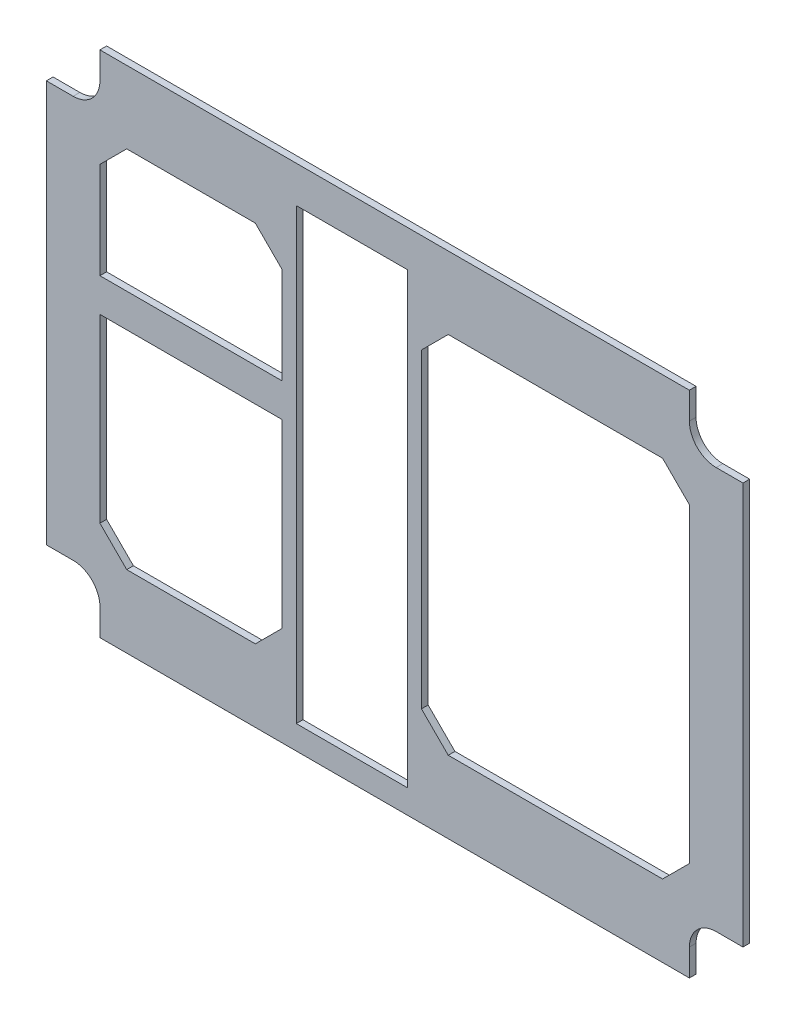
from build123d import *

# Parameters (mm, degrees)
SKETCH1_W           = 20.32
SKETCH1_H           = 100.33
BOSS_EXTRUDE1_DEPTH = 1.5875
SKETCH2_W           = 26.32
SKETCH2_H           = 106.33
CUT_EXTRUDE1_DEPTH  = 2.5875


with BuildPart() as part:
    # Sketch1 → Boss-Extrude1 (new body)
    with BuildSketch(Plane.XY):
        with BuildLine():
            Line((0, -12.7), (-6.35, -12.7))
            ThreePointArc((-6.35, -12.7), (-10.840128061, -10.840128061), (-12.7, -6.35))
            Line((-12.7, -6.35), (-12.7, 0))
            Line((-12.7, 0), (-152.4, 0))
            Line((-152.4, 0), (-152.4, -6.35))
            ThreePointArc((-152.4, -6.35), (-154.259871939, -10.840128061), (-158.75, -12.7))
            Line((-158.75, -12.7), (-165.1, -12.7))
            Line((-165.1, -12.7), (-165.1, -107.95))
            Line((-165.1, -107.95), (-158.75, -107.95))
            ThreePointArc((-158.75, -107.95), (-154.259871939, -109.809871939), (-152.4, -114.3))
            Line((-152.4, -114.3), (-152.4, -120.65))
            Line((-152.4, -120.65), (-12.7, -120.65))
            Line((-12.7, -120.65), (-12.7, -114.3))
            ThreePointArc((-12.7, -114.3), (-10.840128061, -109.809871939), (-6.35, -107.95))
            Line((-6.35, -107.95), (0, -107.95))
            Line((0, -107.95), (0, -12.7))
        make_face()
        with Locations((-92.71, -61.849)):
            Rectangle(SKETCH1_W, SKETCH1_H, mode=Mode.SUBTRACT)
        Polygon((-19.05, -17.145), (-69.85, -17.145), (-76.2, -23.495), (-76.2, -97.155), (-69.85, -103.505), (-19.05, -103.505), (-12.7, -97.155), (-12.7, -23.495), align=None, mode=Mode.SUBTRACT)
        Polygon((-152.4, -23.495), (-152.4, -46.355), (-109.22, -46.355), (-109.22, -23.495), (-115.57, -17.145), (-146.05, -17.145), align=None, mode=Mode.SUBTRACT)
        Polygon((-109.22, -97.155), (-109.22, -54.2925), (-152.4, -54.2925), (-152.4, -97.155), (-146.05, -103.505), (-115.57, -103.505), align=None, mode=Mode.SUBTRACT)
    extrude(amount=BOSS_EXTRUDE1_DEPTH)

    # Sketch2 → Cut-Extrude1 (cut, through all)
    with BuildSketch(Plane(origin=(0, 0, 0), x_dir=(-1, 0, 0), z_dir=(0, 0, -1))):
        with Locations((92.71, -61.849)):
            Rectangle(SKETCH2_W, SKETCH2_H)
    extrude(amount=-CUT_EXTRUDE1_DEPTH, mode=Mode.SUBTRACT)


solid = part.part
